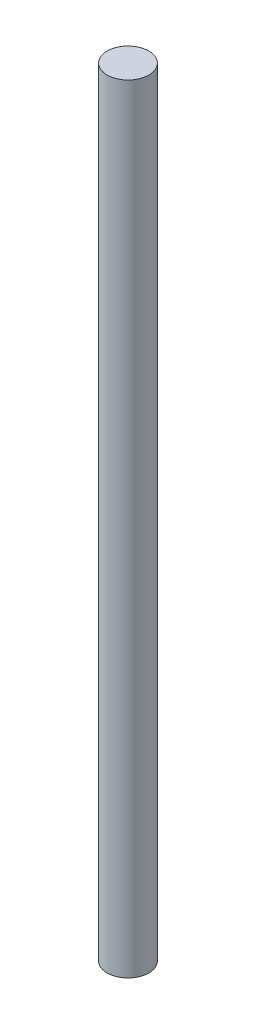
from build123d import *

# Parameters (mm, degrees)
SKETCH1_R           = 4.7625
BOSS_EXTRUDE1_DEPTH = 177.8


with BuildPart() as part:
    # Sketch1 → Boss-Extrude1 (new body)
    with BuildSketch(Plane(origin=(0, 0, 0), x_dir=(1, 0, 0), z_dir=(0, 1, 0))):
        Circle(SKETCH1_R)
    extrude(amount=BOSS_EXTRUDE1_DEPTH)


solid = part.part
